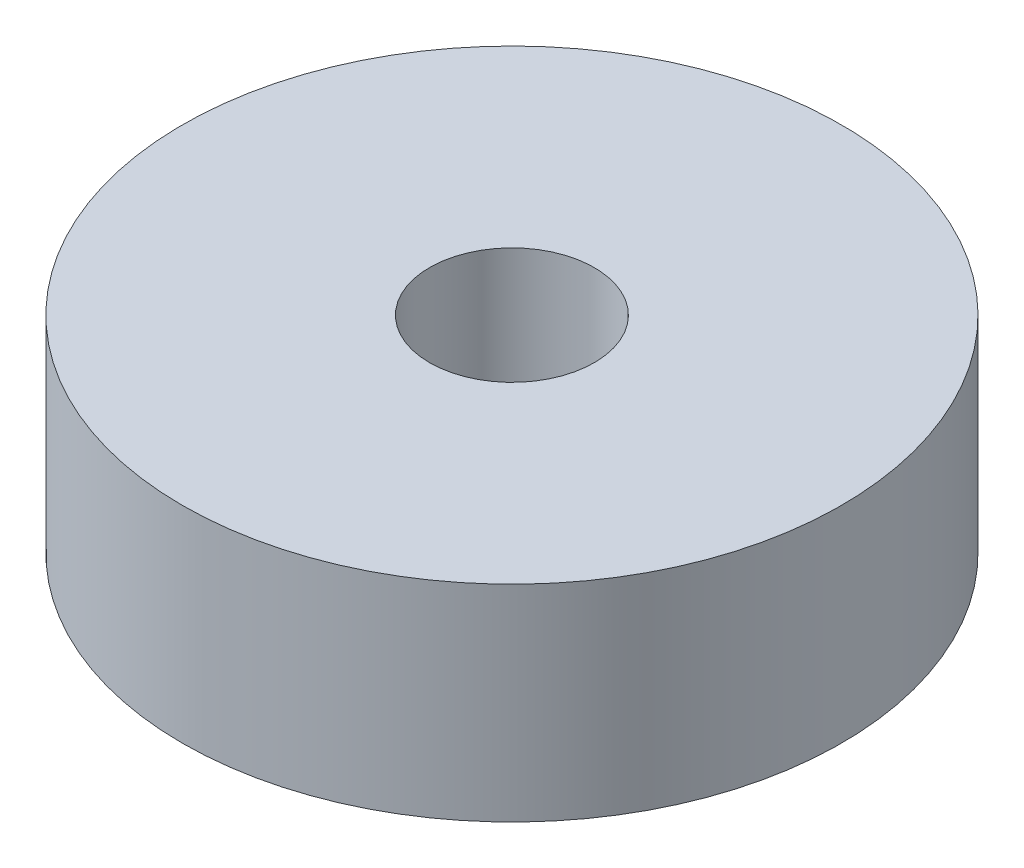
from build123d import *

# Parameters (mm, degrees)
SKETCH_1_R      = 8
SKETCH_1_R_2    = 2
EXTRUDE_1_DEPTH = 5


with BuildPart() as part:
    # 草图1 → 凸台-拉伸1 (new body)
    with BuildSketch(Plane(origin=(0, 0, 0), x_dir=(1, 0, 0), z_dir=(0, 1, 0))):
        Circle(SKETCH_1_R)
        Circle(SKETCH_1_R_2, mode=Mode.SUBTRACT)
    extrude(amount=EXTRUDE_1_DEPTH)


solid = part.part
